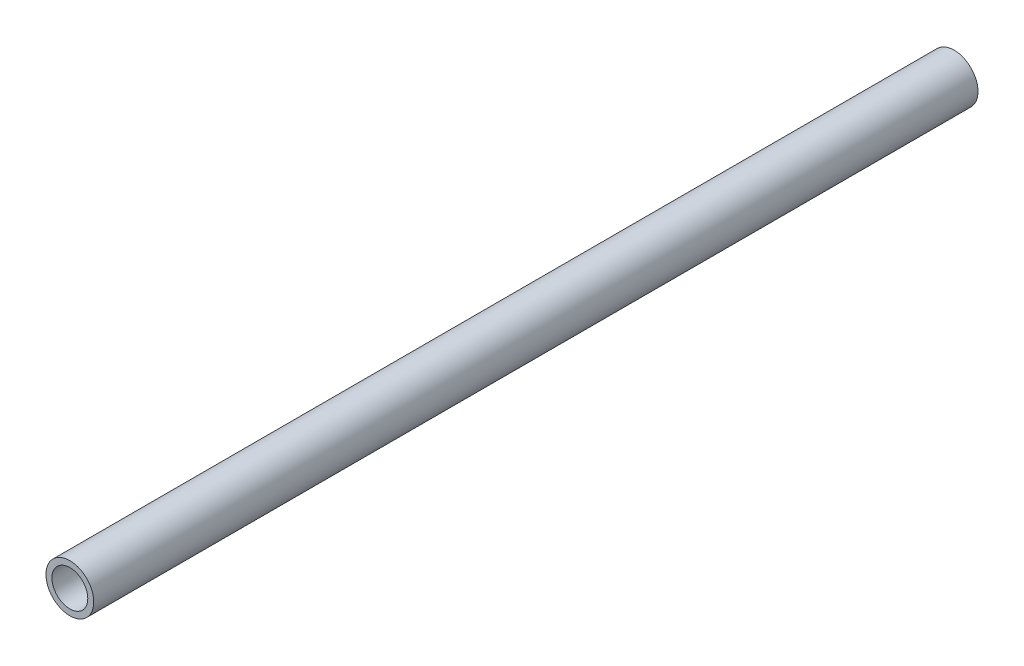
from build123d import *

# Parameters (mm, degrees)
ESQUISSE1_R        = 12.7
ESQUISSE1_R_2      = 9.525
BOSS_EXTRU_1_DEPTH = 469.9


with BuildPart() as part:
    # Esquisse1 → Boss.-Extru.1 (new body)
    with BuildSketch(Plane.XY):
        Circle(ESQUISSE1_R)
        Circle(ESQUISSE1_R_2, mode=Mode.SUBTRACT)
    extrude(amount=BOSS_EXTRU_1_DEPTH)


solid = part.part
